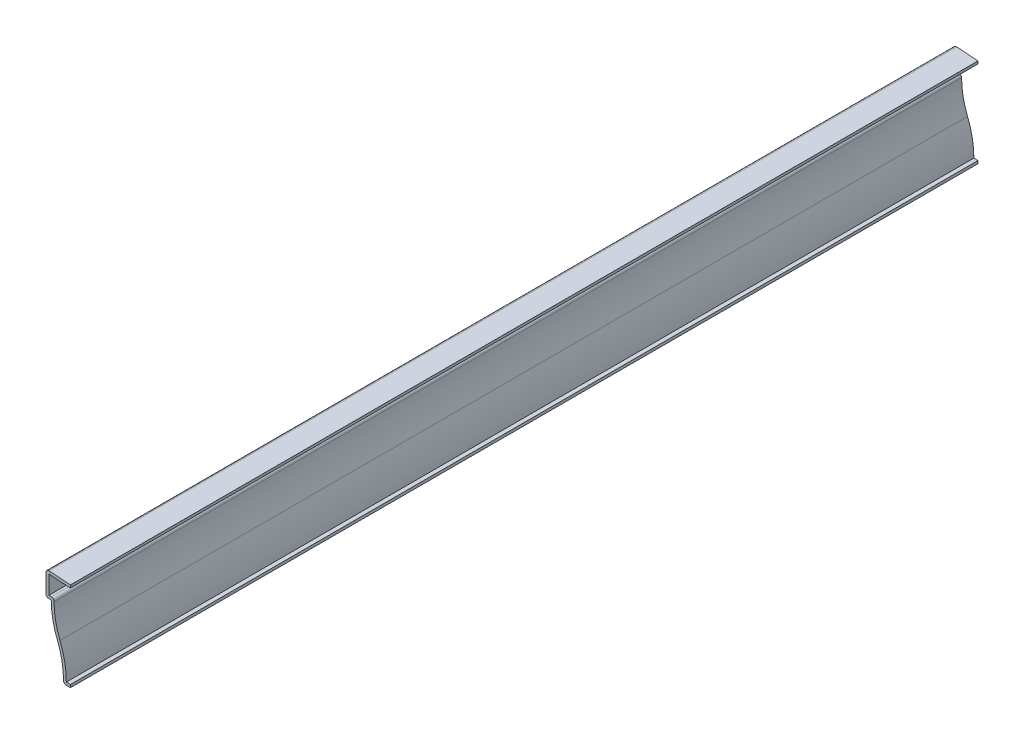
from build123d import *

# Parameters (mm, degrees)
EXTRUDE_THIN1_DEPTH = 412.75
FILLET1_R           = 1.27


with BuildPart() as part:
    # Sketch1 → Extrude-Thin1 (new body)
    with BuildSketch(Plane.XY):
        with BuildLine():
            Line((0, 0), (-3.175, 0))
            ThreePointArc((-3.175, 0), (-3.728678916, 8.031723409), (-5.94070318, 15.772659394))
            ThreePointArc((-5.94070318, 15.772659394), (-8.027174826, 22.833539224), (-8.73125, 30.1625))
            Line((-8.73125, 30.1625), (-11.1125, 30.1625))
            Line((-11.1125, 30.1625), (-11.1125, 41.275))
            Line((-11.1125, 41.275), (0, 40.48125))
            Line((0, 40.48125), (-0.090483753, 39.214477451))
            Line((-0.090483753, 39.214477451), (-9.8425, 39.91105004))
            Line((-9.8425, 39.91105004), (-9.8425, 31.4325))
            Line((-9.8425, 31.4325), (-7.43958058, 31.4325))
            ThreePointArc((-7.43958058, 31.4325), (-6.895991056, 23.69982792), (-4.762762457, 16.247375785))
            ThreePointArc((-4.762762457, 16.247375785), (-2.59675891, 8.898174327), (-1.880316394, 1.27))
            Line((-1.880316394, 1.27), (0, 1.27))
            Line((0, 1.27), (0, 0))
        make_face()
    extrude(amount=-EXTRUDE_THIN1_DEPTH)

    # Fillet1
    fillet1_edges = [part.edges().sort_by_distance(p)[0] for p in [
        (-7.43958058, 31.4325, -206.375),
        (-3.175, 0, -206.375),
        (-11.1125, 30.1625, -206.375),
        (-11.1125, 41.275, -206.375),
    ]]
    fillet(fillet1_edges, radius=FILLET1_R)


solid = part.part
